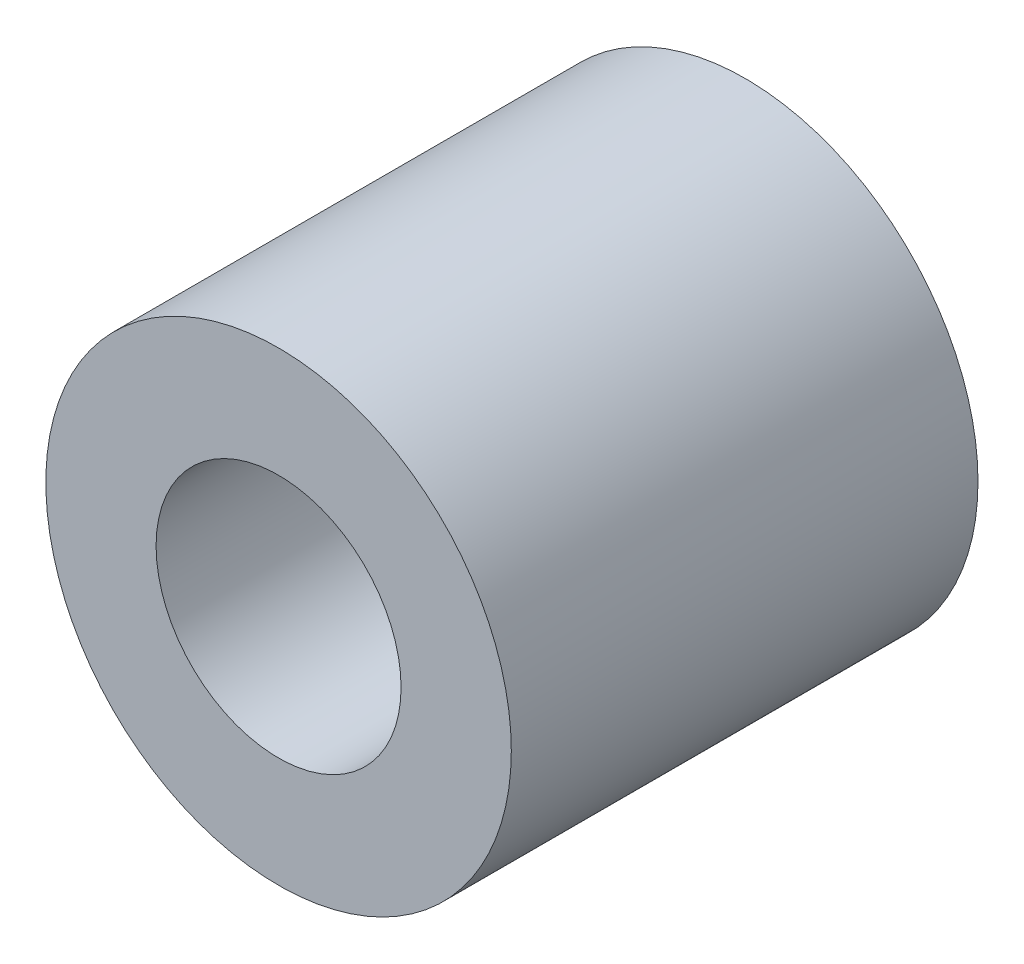
from build123d import *

# Parameters (mm, degrees)
SKETCH1_W = 2.25
SKETCH1_H = 9.525


with BuildPart() as part:
    # Sketch1 → Revolve1 (revolve)
    with BuildSketch(Plane(origin=(0, 0, 0), x_dir=(1, 0, 0), z_dir=(0, 1, 0))):
        with Locations((3.625, 0)):
            Rectangle(SKETCH1_W, SKETCH1_H)
    revolve(axis=Axis((0, 0, -4.7625), (0, 0, 1)))


solid = part.part
